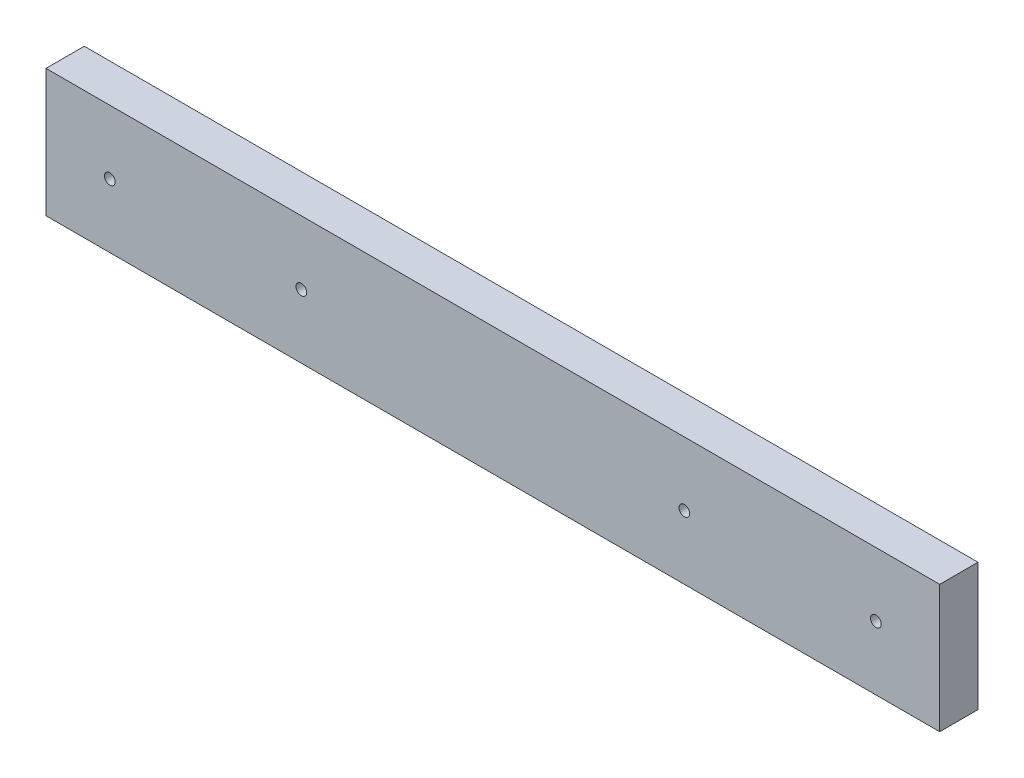
from build123d import *

# Parameters (mm, degrees)
SKIZZE1_W                       = 350
SKIZZE1_H                       = 50
AUFSATZ_LINEAR_AUSTRAGEN1_DEPTH = 15
M5_GEWINDEBOHRUNG1_D            = 4.2
M5_GEWINDEBOHRUNG1_DEPTH        = 12
M5_GEWINDEBOHRUNG1_TIP          = 1.2618073


with BuildPart() as part:
    # Skizze1 → Aufsatz-Linear austragen1 (new body)
    with BuildSketch(Plane.XY):
        Rectangle(SKIZZE1_W, SKIZZE1_H)
    extrude(amount=-AUFSATZ_LINEAR_AUSTRAGEN1_DEPTH)

    # M5 Gewindebohrung1
    with Locations(Plane(origin=(150, 0, 0), x_dir=(1, 0, 0), z_dir=(0, 0, 1))):
        with Locations((0, 0), (-300, 0), (-225, 0), (-75, 0)):
            Hole(M5_GEWINDEBOHRUNG1_D / 2, depth=M5_GEWINDEBOHRUNG1_DEPTH)
            with Locations((0, 0, -(M5_GEWINDEBOHRUNG1_DEPTH + M5_GEWINDEBOHRUNG1_TIP / 2))):  # 118° drill point
                Cone(0, M5_GEWINDEBOHRUNG1_D / 2, M5_GEWINDEBOHRUNG1_TIP, mode=Mode.SUBTRACT)


solid = part.part
